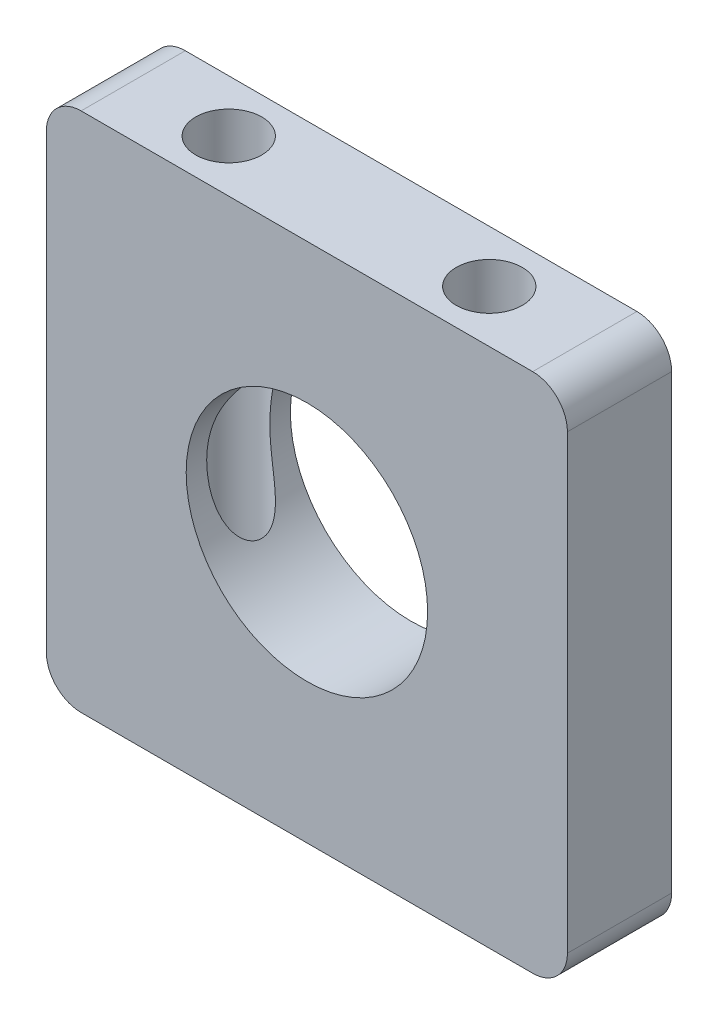
from build123d import *

# Parameters (mm, degrees)
SKETCH1_W           = 38.1
SKETCH1_H           = 38.1
SKETCH1_R           = 8.8265
BOSS_EXTRUDE1_DEPTH = 7.62
FILLET1_R           = 2.54
SKETCH2_R           = 2.413
CUT_EXTRUDE1_DEPTH  = 7.62
SKETCH3_R           = 2.413
CUT_EXTRUDE2_DEPTH  = 7.62
SKETCH4_R           = 2.413
CUT_EXTRUDE3_DEPTH  = 39.1


with BuildPart() as part:
    # Sketch1 → Boss-Extrude1 (new body)
    with BuildSketch(Plane.XY):
        Rectangle(SKETCH1_W, SKETCH1_H)
        Circle(SKETCH1_R, mode=Mode.SUBTRACT)
    extrude(amount=BOSS_EXTRUDE1_DEPTH)

    # Fillet1
    fillet1_edges = [part.edges().sort_by_distance(p)[0] for p in [
        (-19.05, 19.05, 3.81),
        (19.05, 19.05, 3.81),
        (19.05, -19.05, 3.81),
        (-19.05, -19.05, 3.81),
    ]]
    fillet(fillet1_edges, radius=FILLET1_R)

    # Sketch2 → Cut-Extrude1 (cut)
    with BuildSketch(Plane.XZ.offset(19.05)):
        with Locations((9.525, 3.81)):
            Circle(SKETCH2_R)
        with Locations((-9.525, 3.81)):
            Circle(SKETCH2_R)
    extrude(amount=-CUT_EXTRUDE1_DEPTH, mode=Mode.SUBTRACT)

    # Sketch3 → Cut-Extrude2 (cut)
    with BuildSketch(Plane(origin=(0, 19.05, 0), x_dir=(1, 0, 0), z_dir=(0, 1, 0))):
        with Locations((-9.525, -3.81)):
            Circle(SKETCH3_R)
        with Locations((9.525, -3.81)):
            Circle(SKETCH3_R)
    extrude(amount=-CUT_EXTRUDE2_DEPTH, mode=Mode.SUBTRACT)

    # Sketch4 → Cut-Extrude3 (cut, through all)
    with BuildSketch(Plane(origin=(0, 19.05, 0), x_dir=(1, 0, 0), z_dir=(0, 1, 0))):
        with Locations((9.525, -3.81)):
            Circle(SKETCH4_R)
        with Locations((-9.525, -3.81)):
            Circle(SKETCH4_R)
    extrude(amount=-CUT_EXTRUDE3_DEPTH, mode=Mode.SUBTRACT)


solid = part.part
